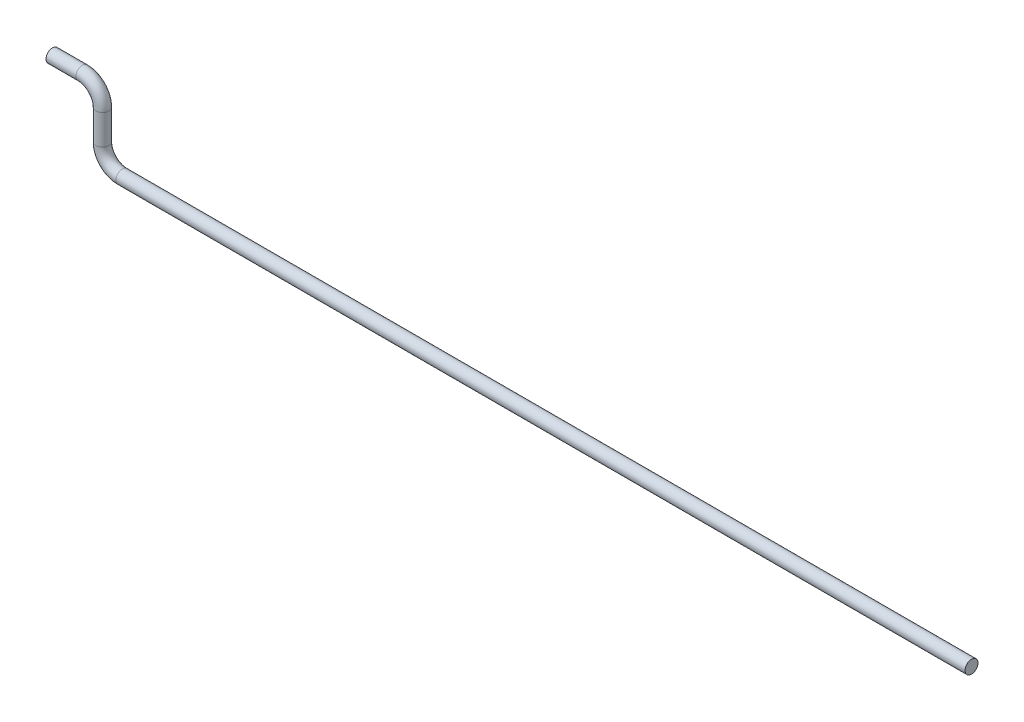
from build123d import *

# Parameters (mm, degrees)
SKETCH2_R = 0.65


with BuildPart() as part:
    # Sweep1: sweep along a path in Sketch1
    with BuildLine(Plane.XY) as sweep1_path:
        Line((85, 0), (0, 0))
        ThreePointArc((0, 0), (-1.414213562, 0.585786438), (-2, 2))
        Line((-2, 2), (-2, 5))
        ThreePointArc((-2, 5), (-2.585786438, 6.414213562), (-4, 7))
        Line((-4, 7), (-7, 7))
    # Sketch2 → Sweep1 (sweep)
    with BuildSketch(Plane(origin=(85, 0, 0), x_dir=(0, 0, -1), z_dir=(1, 0, 0))):
        Circle(SKETCH2_R)
    sweep(path=sweep1_path.line)


solid = part.part
